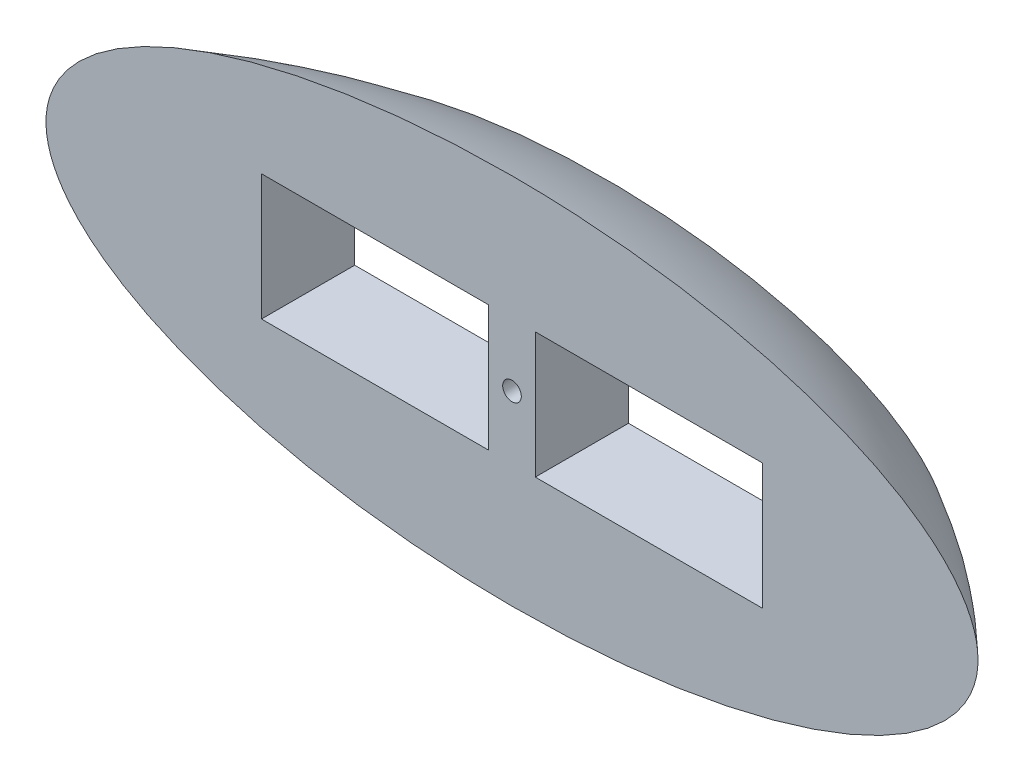
from build123d import *

# Parameters (mm, degrees)
BEAM_SCALE_X           = 1
BEAM_SCALE_Y           = 4
BEAM_SCALE_Z           = 1
LENGTH_SCALE_X         = 10
LENGTH_SCALE_Y         = 1
LENGTH_SCALE_Z         = 1
PAYLOAD_BAY_DEPTH      = 292.823782601
PAYLOAD_BAY_DEPTH_BACK = 63.5
SKETCH6_W              = 123.825
SKETCH6_H              = 68.58
MAST_HOLE_DEPTH        = 292.823782601
MAST_HOLE_DEPTH_BACK   = 101.6
SKETCH16_R             = 5.08
SKETCH15_2_W           = 508
SKETCH15_2_H           = 203.2
LAYER_2_DEPTH          = 50.8


with BuildPart() as part:
    # YZ Section_depthOnly → Depth (revolve)
    with BuildSketch(Plane(origin=(0, 0, 0), x_dir=(0, 0, -1), z_dir=(1, 0, 0))):
        with BuildLine():
            Line((0, 0), (0, -25.4))
            add(Edge.make_bspline(
                [(0, -25.4), (101.6, -14.816666667), (101.6, 0)],
                knots=[5.507991934, 5.507991934, 5.507991934, 6.283185307, 6.283185307, 6.283185307], degree=2, weights=[1, 0.9258201, 1]))
            Line((101.6, 0), (0, 0))
        make_face()
    revolve(axis=Axis((0, 0, 254), (0, 0, -1)))

    # Sketch13 → Height (revolve)
    with BuildSketch(Plane(origin=(0, 0, 0), x_dir=(0, 0, -1), z_dir=(1, 0, 0))):
        with BuildLine():
            Line((0, 0), (-50.8, 0))
            add(Edge.make_bspline(
                [(-50.8, 0), (-50.8, -23.988888889), (0, -25.4)],
                knots=[0, 0, 0, 1.511938821, 1.511938821, 1.511938821], degree=2, weights=[1, 0.727606875, 1]))
            Line((0, -25.4), (0, 0))
        make_face()
    revolve(axis=Axis((0, 0, 0), (0, 0, 1)))


with BuildPart() as part_1:
    # Beam: scaled about (0, 0, 0)
    add(part.part.scale((BEAM_SCALE_X, BEAM_SCALE_Y, BEAM_SCALE_Z), about=(0, 0, 0)))


with BuildPart() as part_2:
    # Length: scaled about (0, 0, 0)
    add(part_1.part.scale((LENGTH_SCALE_X, LENGTH_SCALE_Y, LENGTH_SCALE_Z), about=(0, 0, 0)))

    # Sketch6 → Payload Bay (cut, two sides: drawn at the far end of the back side and taken through both)
    with BuildSketch(Plane.XY.offset(-PAYLOAD_BAY_DEPTH_BACK)):
        with Locations((-74.6125, 0)):
            Rectangle(SKETCH6_W, SKETCH6_H)
        with Locations((74.6125, 0)):
            Rectangle(SKETCH6_W, SKETCH6_H)
    extrude(amount=PAYLOAD_BAY_DEPTH + PAYLOAD_BAY_DEPTH_BACK, mode=Mode.SUBTRACT)

    # Sketch16 → Mast Hole (cut, two sides: drawn at the far end of the back side and taken through both)
    with BuildSketch(Plane.XY.offset(-MAST_HOLE_DEPTH_BACK)):
        Circle(SKETCH16_R)
    extrude(amount=MAST_HOLE_DEPTH + MAST_HOLE_DEPTH_BACK, mode=Mode.SUBTRACT)


with BuildPart() as body_2:
    # Sketch15_2 → Layer 2 (new body)
    with BuildSketch(Plane.XY):
        Rectangle(SKETCH15_2_W, SKETCH15_2_H)
    extrude(amount=-LAYER_2_DEPTH)


with BuildPart() as part_3:
    add(part_2.part)

    # Layer 2 Body: intersect body 2
    add(body_2.part, mode=Mode.INTERSECT)


solid = part_3.part
